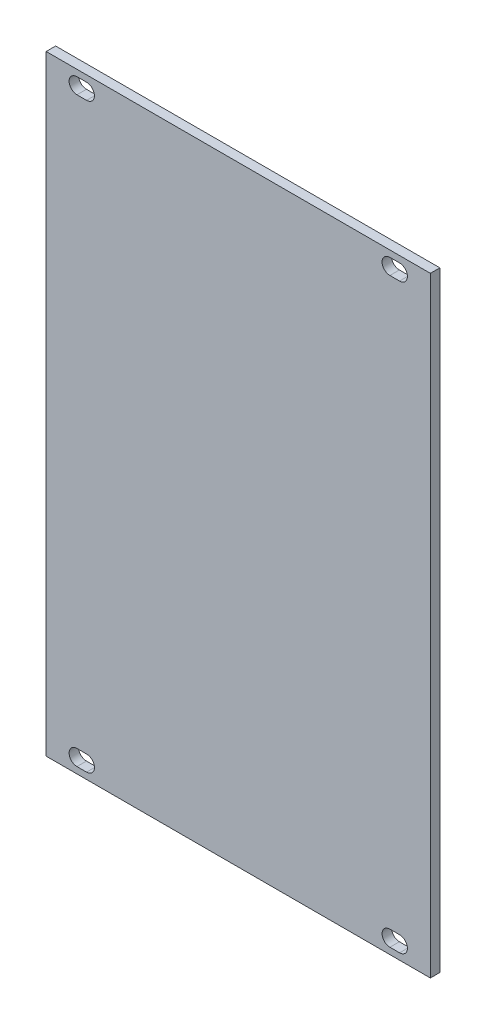
from build123d import *

# Parameters (mm, degrees)
SKETCH1_W           = 80.9
SKETCH1_H           = 128.5
BOSS_EXTRUDE1_DEPTH = 2


with BuildPart() as part:
    # Sketch1 → Boss-Extrude1 (new body)
    with BuildSketch(Plane.XY):
        Rectangle(SKETCH1_W, SKETCH1_H)
        with BuildLine():
            Line((-33.966, -59.6), (-31.934, -59.6))
            ThreePointArc((-31.934, -59.6), (-30.284, -61.25), (-31.934, -62.9))
            Line((-31.934, -62.9), (-33.966, -62.9))
            ThreePointArc((-33.966, -62.9), (-35.616, -61.25), (-33.966, -59.6))
        make_face(mode=Mode.SUBTRACT)
        with BuildLine():
            Line((-33.966, 62.9), (-31.934, 62.9))
            ThreePointArc((-31.934, 62.9), (-30.284, 61.25), (-31.934, 59.6))
            Line((-31.934, 59.6), (-33.966, 59.6))
            ThreePointArc((-33.966, 59.6), (-35.616, 61.25), (-33.966, 62.9))
        make_face(mode=Mode.SUBTRACT)
        with BuildLine():
            Line((31.934000014, 62.9), (33.966000014, 62.9))
            ThreePointArc((33.966000014, 62.9), (35.616000014, 61.25), (33.966000014, 59.6))
            Line((33.966000014, 59.6), (31.934000014, 59.6))
            ThreePointArc((31.934000014, 59.6), (30.284000014, 61.25), (31.934000014, 62.9))
        make_face(mode=Mode.SUBTRACT)
        with BuildLine():
            Line((31.934000014, -59.6), (33.966000014, -59.6))
            ThreePointArc((33.966000014, -59.6), (35.616000014, -61.25), (33.966000014, -62.9))
            Line((33.966000014, -62.9), (31.934000014, -62.9))
            ThreePointArc((31.934000014, -62.9), (30.284000014, -61.25), (31.934000014, -59.6))
        make_face(mode=Mode.SUBTRACT)
    extrude(amount=BOSS_EXTRUDE1_DEPTH)


solid = part.part
